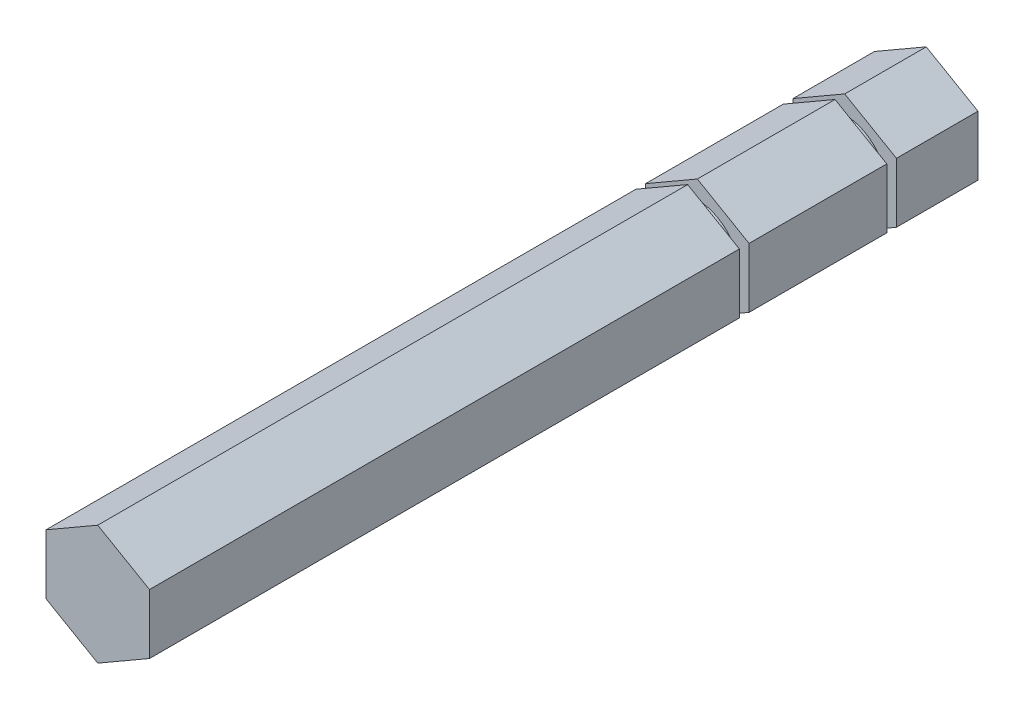
from build123d import *

# Parameters (mm, degrees)
BOSS_EXTRUDE1_DEPTH = 76.2508
SKETCH5_W           = 11.10345239
SKETCH5_H           = 12.145052052
SKETCH5_R           = 3.8481
CUT_EXTRUDE2_DEPTH  = 0.4445
SKETCH6_W           = 10.752068687
SKETCH6_H           = 11.509710708
SKETCH6_R           = 3.8481
CUT_EXTRUDE3_DEPTH  = 0.4445


with BuildPart() as part:
    # Sketch1 → Boss-Extrude1 (new body)
    with BuildSketch(Plane.XY):
        Polygon((0, 5.499261314), (-4.7625, 2.749630657), (-4.7625, -2.749630657), (0, -5.499261314), (4.7625, -2.749630657), (4.7625, 2.749630657), align=None)
    extrude(amount=BOSS_EXTRUDE1_DEPTH)

    # Sketch5 → Cut-Extrude2 (cut, symmetric)
    with BuildSketch(Plane(origin=(0, 0, 21.5138), x_dir=(-1, 0, 0), z_dir=(0, 0, -1))):
        with Locations((-0.378227241, -0.09440181)):
            Rectangle(SKETCH5_W, SKETCH5_H)
        Circle(SKETCH5_R, mode=Mode.SUBTRACT)
    extrude(amount=CUT_EXTRUDE2_DEPTH, both=True, mode=Mode.SUBTRACT)

    # Sketch6 → Cut-Extrude3 (cut, symmetric)
    with BuildSketch(Plane(origin=(0, 0, 7.9502), x_dir=(-1, 0, 0), z_dir=(0, 0, -1))):
        with Locations((-0.265980709, -0.185380495)):
            Rectangle(SKETCH6_W, SKETCH6_H)
        Circle(SKETCH6_R, mode=Mode.SUBTRACT)
    extrude(amount=CUT_EXTRUDE3_DEPTH, both=True, mode=Mode.SUBTRACT)


solid = part.part
